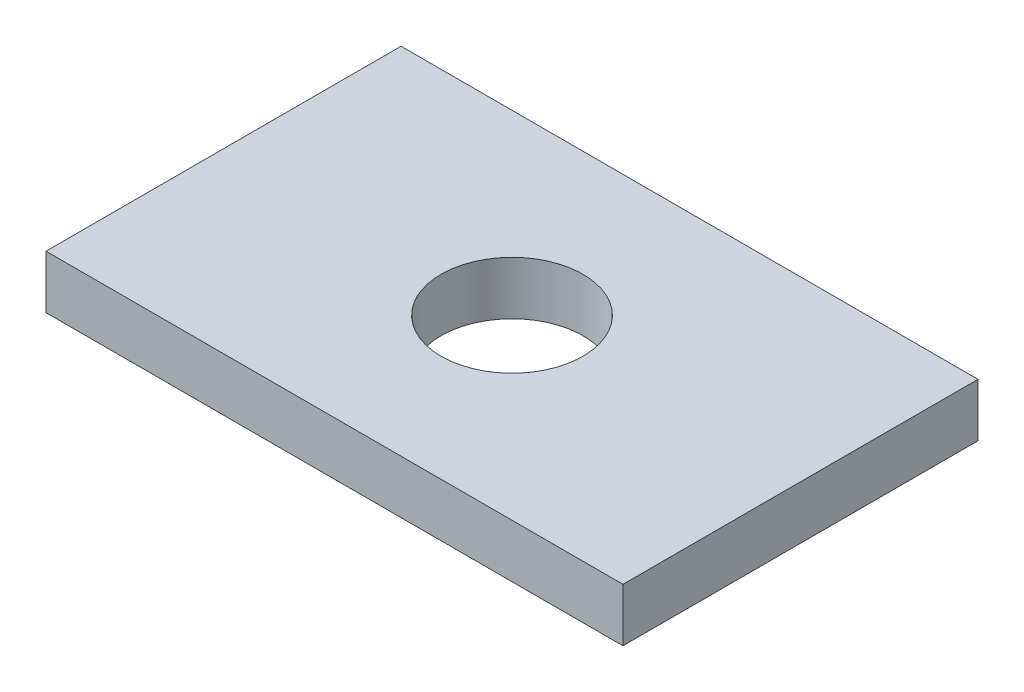
from build123d import *

# Parameters (mm, degrees)
SKETCH1_W           = 65
SKETCH1_H           = 6
BOSS_EXTRUDE1_DEPTH = 40
SKETCH2_R           = 8
CUT_EXTRUDE1_DEPTH  = 7


with BuildPart() as part:
    # Sketch1 → Boss-Extrude1 (new body)
    with BuildSketch(Plane.XY):
        Rectangle(SKETCH1_W, SKETCH1_H)
    extrude(amount=BOSS_EXTRUDE1_DEPTH)

    # Sketch2 → Cut-Extrude1 (cut, through all)
    with BuildSketch(Plane(origin=(0, 3, 0), x_dir=(1, 0, 0), z_dir=(0, 1, 0))):
        with Locations((0, -20)):
            Circle(SKETCH2_R)
    extrude(amount=-CUT_EXTRUDE1_DEPTH, mode=Mode.SUBTRACT)


solid = part.part
